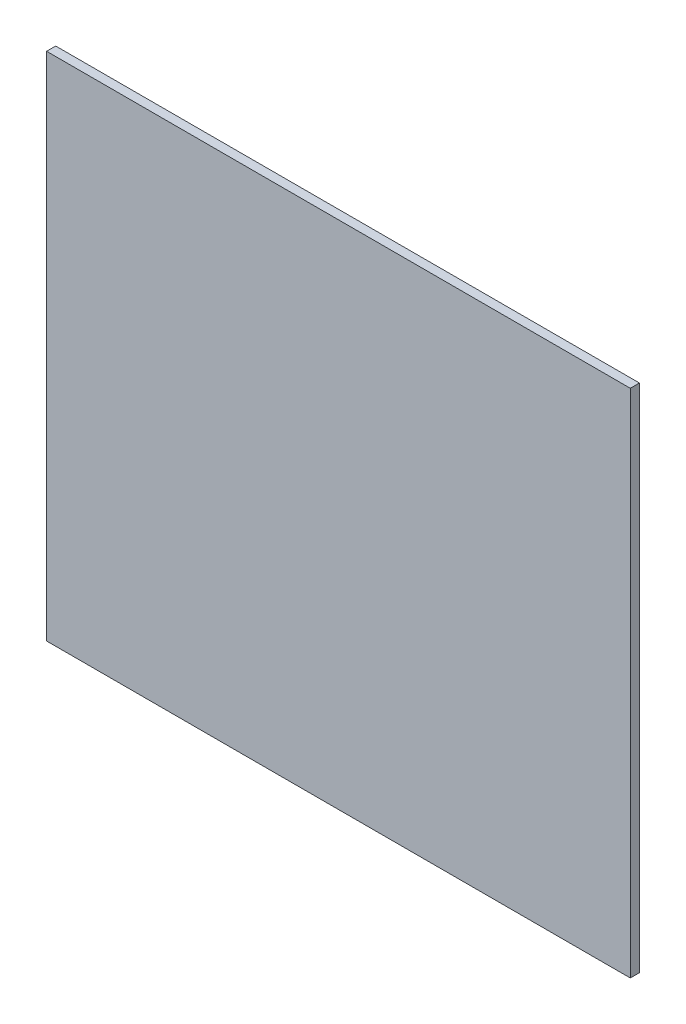
from build123d import *

# Parameters (mm, degrees)
SKETCH1_W           = 203.2
SKETCH1_H           = 177.8
BOSS_EXTRUDE1_DEPTH = 3.175


with BuildPart() as part:
    # Sketch1 → Boss-Extrude1 (new body)
    with BuildSketch(Plane.XY):
        with Locations((65.919888734, -64.171210014)):
            Rectangle(SKETCH1_W, SKETCH1_H)
    extrude(amount=BOSS_EXTRUDE1_DEPTH)


solid = part.part
